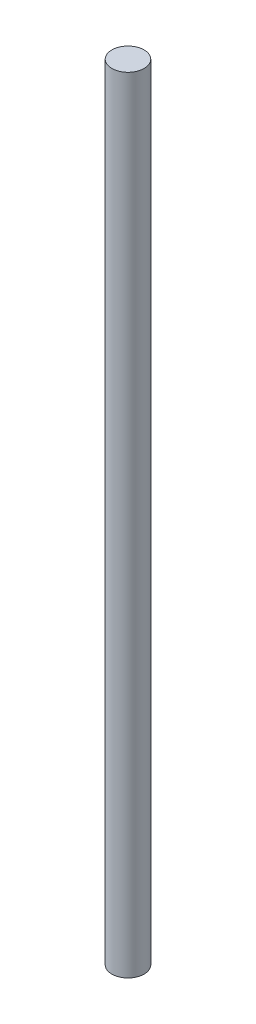
from build123d import *

# Parameters (mm, degrees)
SKETCH1_R           = 3
BOSS_EXTRUDE1_DEPTH = 146


with BuildPart() as part:
    # Sketch1 → Boss-Extrude1 (new body)
    with BuildSketch(Plane(origin=(0, 0, 0), x_dir=(1, 0, 0), z_dir=(0, 1, 0))):
        Circle(SKETCH1_R)
    extrude(amount=BOSS_EXTRUDE1_DEPTH)


solid = part.part
